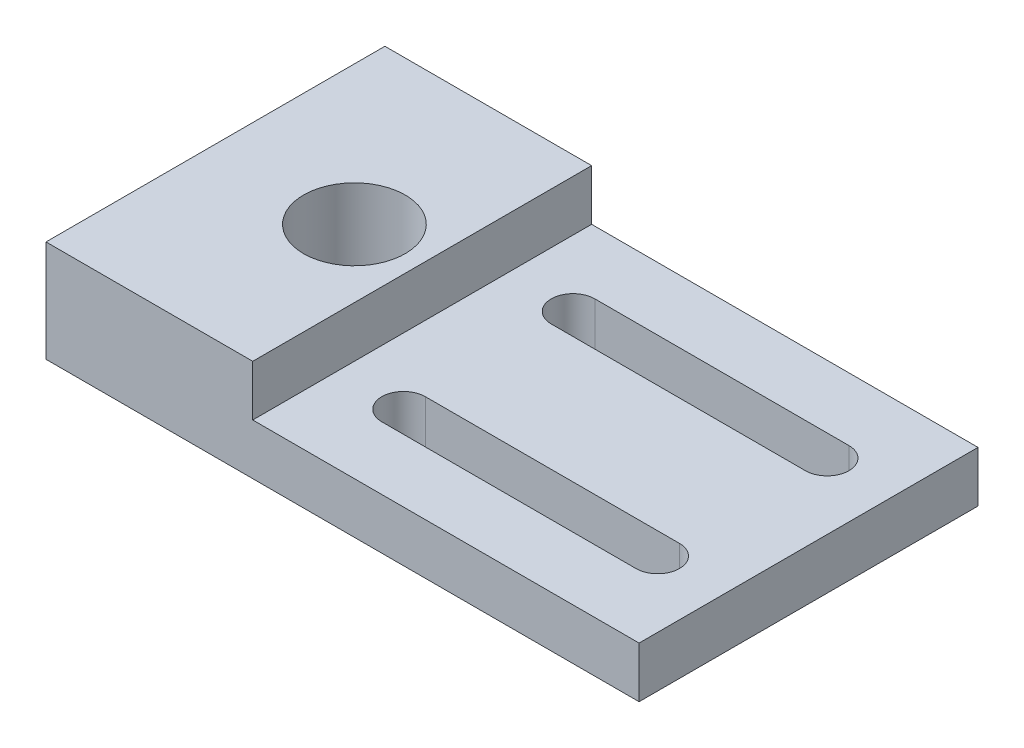
from build123d import *

# Parameters (mm, degrees)
BOSS_EXTRUDE1_DEPTH = 12.7
SKETCH2_R           = 3.81
CUT_EXTRUDE1_DEPTH  = 8.62


with BuildPart() as part:
    # Sketch1 → Boss-Extrude1 (new body, symmetric)
    with BuildSketch(Plane.XY):
        Polygon((-22.225, 7.62), (-6.731, 7.62), (-6.731, 3.81), (22.225, 3.81), (22.225, 0), (-22.225, 0), align=None)
    extrude(amount=BOSS_EXTRUDE1_DEPTH, both=True)

    # Sketch2 → Cut-Extrude1 (cut, through all)
    with BuildSketch(Plane(origin=(0, 7.62, 0), x_dir=(1, 0, 0), z_dir=(0, 1, 0))):
        with Locations((-11.811, 0)):
            Circle(SKETCH2_R)
        with BuildLine():
            Line((-1.778, 7.98195), (17.272, 7.98195))
            ThreePointArc((17.272, 7.98195), (18.90395, 6.35), (17.272, 4.71805))
            Line((17.272, 4.71805), (-1.778, 4.71805))
            ThreePointArc((-1.778, 4.71805), (-3.40995, 6.35), (-1.778, 7.98195))
        make_face()
        with BuildLine():
            Line((-1.778, -4.71805), (17.272, -4.71805))
            ThreePointArc((17.272, -4.71805), (18.90395, -6.35), (17.272, -7.98195))
            Line((17.272, -7.98195), (-1.778, -7.98195))
            ThreePointArc((-1.778, -7.98195), (-3.40995, -6.35), (-1.778, -4.71805))
        make_face()
    extrude(amount=-CUT_EXTRUDE1_DEPTH, mode=Mode.SUBTRACT)


solid = part.part
